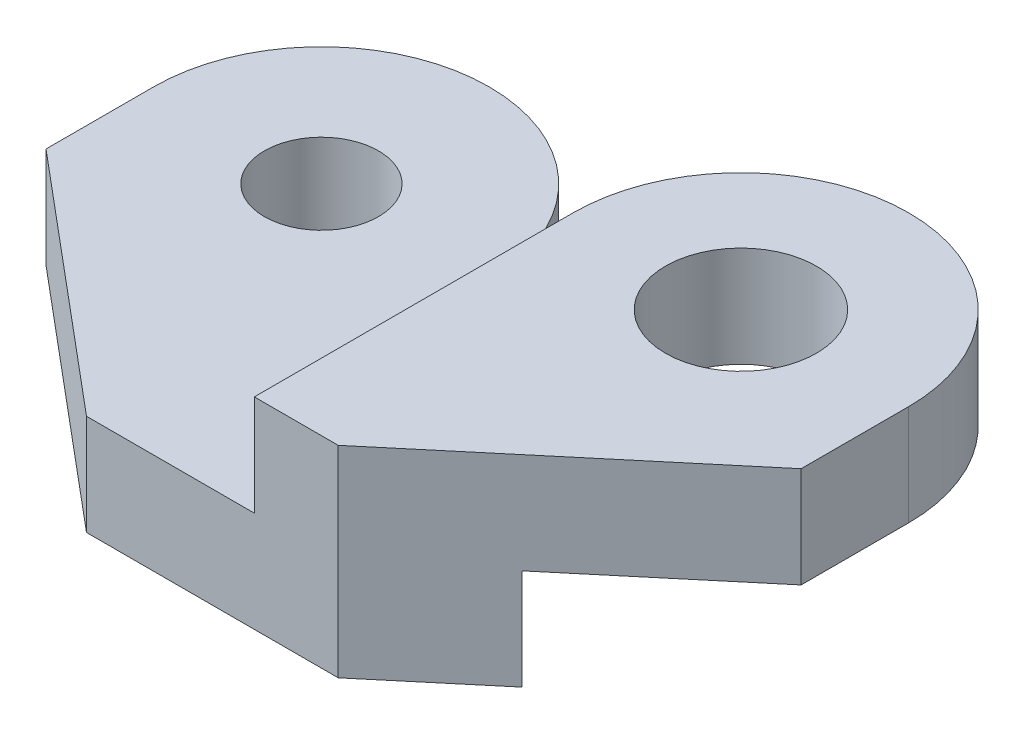
from build123d import *

# Parameters (mm, degrees)
BOSS_EXTRU_1_DEPTH      = 6
BOSS_EXTRU_2_DEPTH      = 12
ESQUISSE14_W            = 21
ESQUISSE14_H            = 6
ENL_V_MAT_EXTRU_2_DEPTH = 21
D_GAGEMENT_M81_D        = 9
TROU_TARAUD_M82_D       = 6.8
ESQUISSE19_W            = 31.228123836
ESQUISSE19_H            = 16.033363116
ENL_V_MAT_EXTRU_3_DEPTH = 22
ESQUISSE20_W            = 8
ESQUISSE20_H            = 6
BOSS_EXTRU_3_DEPTH      = 25
BOSS_EXTRU_4_DEPTH      = 6
TROU_TARAUD_M83_D       = 6.8
ESQUISSE25_W            = 25
ESQUISSE25_H            = 6
ENL_V_MAT_EXTRU_4_DEPTH = 3
ENL_V_START             = -13
ENL_V_MAT_EXTRU_5_DEPTH = 14


with BuildPart() as part:
    # Esquisse1 → Boss.-Extru.1 (new body)
    with BuildSketch(Plane(origin=(0, 0, 0), x_dir=(1, 0, 0), z_dir=(0, 1, 0))):
        with BuildLine():
            Line((0, 0), (0, 30))
            ThreePointArc((0, 30), (10, 40), (20, 30))
            Line((20, 30), (20, 0))
            ThreePointArc((20, 0), (10, -10), (0, 0))
        make_face()
    extrude(amount=BOSS_EXTRU_1_DEPTH)

    # Esquisse12 → Boss.-Extru.2 (add)
    with BuildSketch(Plane.XZ):
        with BuildLine():
            Line((0, -30), (20, -30))
            Line((20, -30), (20, 0))
            ThreePointArc((20, 0), (10, 10), (0, 0))
            Line((0, 0), (0, -30))
        make_face()
    extrude(amount=BOSS_EXTRU_2_DEPTH)

    # Esquisse14 → Enlèv. mat.-Extru.2 (cut, through all)
    with BuildSketch(Plane(origin=(20, 0, 0), x_dir=(0, 0, -1), z_dir=(1, 0, 0))):
        with Locations((0.5, 3)):
            Rectangle(ESQUISSE14_W, ESQUISSE14_H)
        Polygon((30, 0), (19, 0), (19, -6), (-10, -6), (-10, -12), (30, -12), align=None)
    extrude(amount=-ENL_V_MAT_EXTRU_2_DEPTH, mode=Mode.SUBTRACT)

    # Dégagement M81 (through all)
    with Locations(Plane(origin=(0, 6, 0), x_dir=(1, 0, 0), z_dir=(0, 1, 0))):
        with Locations((10, 30)):
            Hole(D_GAGEMENT_M81_D / 2)

    # Trou taraudé M82 (through all)
    with Locations(Plane(origin=(0, 0, 0), x_dir=(1, 0, 0), z_dir=(0, 1, 0))):
        with Locations((10, 0)):
            Hole(TROU_TARAUD_M82_D / 2)

    # Esquisse19 → Enlèv. mat.-Extru.3 (cut, through all)
    with BuildSketch(Plane.XY.offset(-11)):
        with Locations((8.695037224, -0.70266631)):
            Rectangle(ESQUISSE19_W, ESQUISSE19_H)
    extrude(amount=ENL_V_MAT_EXTRU_3_DEPTH, mode=Mode.SUBTRACT)

    # Esquisse20 → Boss.-Extru.3 (add)
    with BuildSketch(Plane.ZY):
        with Locations((-15, -3)):
            Rectangle(ESQUISSE20_W, ESQUISSE20_H)
    extrude(amount=BOSS_EXTRU_3_DEPTH)

    # Esquisse21 → Boss.-Extru.4 (add)
    with BuildSketch(Plane.XZ.offset(6)):
        with BuildLine():
            Line((-25, -19), (-25, -30))
            ThreePointArc((-25, -30), (-15, -40), (-5, -30))
            Line((-5, -30), (-5, -19))
            Line((-5, -19), (-25, -19))
        make_face()
    extrude(amount=-BOSS_EXTRU_4_DEPTH)

    # Trou taraudé M83 (through all)
    with Locations(Plane(origin=(0, 0, 0), x_dir=(1, 0, 0), z_dir=(0, 1, 0))):
        with Locations((-15, 30)):
            Hole(TROU_TARAUD_M83_D / 2)

    # Esquisse25 → Enlèv. mat.-Extru.4 (cut)
    with BuildSketch(Plane(origin=(0, 0, -19), x_dir=(-1, 0, 0), z_dir=(0, 0, -1))):
        with Locations((-7.5, -3)):
            Rectangle(ESQUISSE25_W, ESQUISSE25_H)
    extrude(amount=-ENL_V_MAT_EXTRU_4_DEPTH, mode=Mode.SUBTRACT)

    # Esquisse27 → Enlèv. mat.-Extru.5 (cut)
    with BuildSketch(Plane.XZ.offset(6).offset(ENL_V_START)):
        Polygon((-25, -11), (-10, -11), (-25, -23.586494468), align=None)
    enl_v_mat_extru_5 = extrude(amount=ENL_V_MAT_EXTRU_5_DEPTH, mode=Mode.SUBTRACT)

    # Symétrie1: Enlèv. mat.-Extru.5 across plane
    add(enl_v_mat_extru_5.mirror(Plane(origin=(-2.5, 0, 0), x_dir=(0, 0, 1), z_dir=(1, 0, 0))), mode=Mode.SUBTRACT)


solid = part.part
